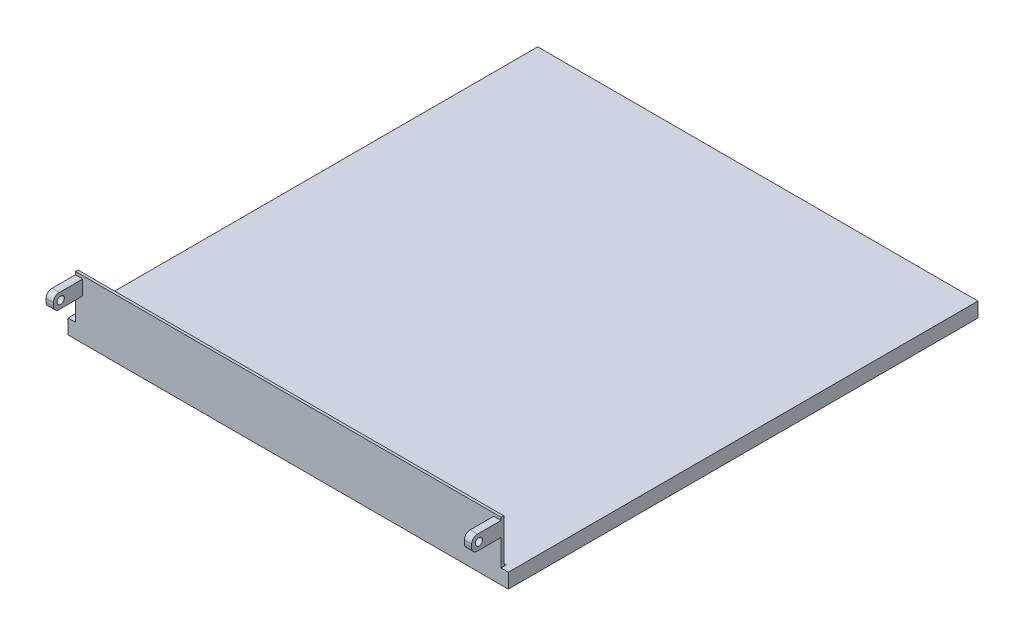
from build123d import *

# Parameters (mm, degrees)
SKETCH1_W                = 381
SKETCH1_H                = 406.4
BOSS_EXTRUDE1_DEPTH      = 12.7
CUT_EXTRUDE1_DEPTH       = 530.86
BOSS_EXTRUDE2_DEPTH      = 190.5
BOSS_EXTRUDE2_DEPTH_BACK = 190.5
CUT_EXTRUDE2_DEPTH       = 185.42
CUT_EXTRUDE2_DEPTH_BACK  = 185.42
SKETCH9_W                = 370.84
SKETCH9_H                = 38.1
BOSS_EXTRUDE3_DEPTH      = 203.2
SKETCH9_2_W              = 370.84
SKETCH9_2_H              = 38.1
CUT_EXTRUDE3_DEPTH       = 200.66
FILLET12_R               = 2.54
SKETCH20_W               = 381
SKETCH20_H               = 12.7
BOSS_EXTRUDE5_DEPTH      = 406.4
CUT_EXTRUDE10_DEPTH      = 304.8
CUT_EXTRUDE10_DEPTH_BACK = 259.334
SKETCH27_W               = 25.4
SKETCH27_H               = 12.7
SKETCH27_R               = 3.175
BOSS_EXTRUDE6_DEPTH      = 184.15
BOSS_EXTRUDE6_DEPTH_BACK = 184.15
SKETCH27_2_W             = 25.4
SKETCH27_2_H             = 12.7
SKETCH27_2_R             = 3.175
CUT_EXTRUDE11_DEPTH      = 177.8
CUT_EXTRUDE11_DEPTH_BACK = 177.8
FILLET14_R               = 5.08
SKETCH29_W               = 6.35
SKETCH29_H               = 38.1
CUT_EXTRUDE12_DEPTH      = 229.6
CUT_EXTRUDE12_DEPTH_BACK = 204.2000001


with BuildPart() as part:
    # Sketch1 → Boss-Extrude1 (new body)
    with BuildSketch(Plane(origin=(0, 0, 0), x_dir=(1, 0, 0), z_dir=(0, 1, 0))):
        Rectangle(SKETCH1_W, SKETCH1_H)
    extrude(amount=-BOSS_EXTRUDE1_DEPTH)

    # Sketch5 → Cut-Extrude1 (cut)
    with BuildSketch(Plane(origin=(0, 0, -203.2), x_dir=(-1, 0, 0), z_dir=(0, 0, -1))):
        Polygon((190.5, 0), (0, -12.7), (190.5, -12.7), align=None)
        Polygon((0, -12.7), (-190.5, 0), (-190.5, -12.7), align=None)
    extrude(amount=-CUT_EXTRUDE1_DEPTH, mode=Mode.SUBTRACT)

    # Sketch6 → Boss-Extrude2 (add, two sides)
    with BuildSketch(Plane(origin=(0, 0, 0), x_dir=(0, 0, -1), z_dir=(1, 0, 0))) as boss_extrude2_sk:
        with BuildLine():
            Line((-203.2, 0), (-203.2, 38.1))
            add(Edge.make_bspline(
                [(-203.2, 38.1), (-139.671233151, 43.854392756), (-4.575804842, 44.131584557), (127.011271564, 22.260123732), (203.2, 0)],
                knots=[0, 0, 0, 0, 0.446112954, 1, 1, 1, 1], degree=3))
            Line((203.2, 0), (-203.2, 0))
        make_face()
    extrude(amount=BOSS_EXTRUDE2_DEPTH)
    extrude(boss_extrude2_sk.sketch, amount=-BOSS_EXTRUDE2_DEPTH_BACK)

    # Sketch6_2 → Cut-Extrude2 (cut, two sides)
    with BuildSketch(Plane(origin=(0, 0, 0), x_dir=(0, 0, -1), z_dir=(1, 0, 0))) as cut_extrude2_sk:
        with BuildLine():
            Line((-203.2, 0), (-203.2, 38.1))
            add(Edge.make_bspline(
                [(-203.2, 38.1), (-139.671233151, 43.854392756), (-4.575804842, 44.131584557), (127.011271564, 22.260123732), (203.2, 0)],
                knots=[0, 0, 0, 0, 0.446112954, 1, 1, 1, 1], degree=3))
            Line((203.2, 0), (-203.2, 0))
        make_face()
    extrude(amount=CUT_EXTRUDE2_DEPTH, mode=Mode.SUBTRACT)
    extrude(cut_extrude2_sk.sketch, amount=-CUT_EXTRUDE2_DEPTH_BACK, mode=Mode.SUBTRACT)

    # Sketch9 → Boss-Extrude3 (add)
    with BuildSketch(Plane.XY):
        with Locations((0, 19.05)):
            Rectangle(SKETCH9_W, SKETCH9_H)
    extrude(amount=BOSS_EXTRUDE3_DEPTH)

    # Sketch9_2 → Cut-Extrude3 (cut)
    with BuildSketch(Plane.XY):
        with Locations((0, 19.05)):
            Rectangle(SKETCH9_2_W, SKETCH9_2_H)
    extrude(amount=CUT_EXTRUDE3_DEPTH, mode=Mode.SUBTRACT)

    # Fillet12
    fillet12_edges = [part.edges().sort_by_distance(p)[0] for p in [
        (0, 0, 200.66),
    ]]
    fillet(fillet12_edges, radius=FILLET12_R)

    # Sketch20 → Boss-Extrude5 (add)
    with BuildSketch(Plane.XY.offset(203.2)):
        with Locations((0, -6.35)):
            Rectangle(SKETCH20_W, SKETCH20_H)
    extrude(amount=-BOSS_EXTRUDE5_DEPTH)

    # Sketch21 → Cut-Extrude10 (cut, two sides)
    with BuildSketch(Plane(origin=(0, 0, 0), x_dir=(0, 0, -1), z_dir=(1, 0, 0))) as cut_extrude10_sk:
        with BuildLine():
            Line((-203.2, 38.1), (-203.2, 89.275464314))
            Line((-203.2, 89.275464314), (140.49634993, 63.687732157))
            Line((140.49634993, 63.687732157), (140.49634993, 16.247140788))
            add(Edge.make_bspline(
                [(-203.2, 38.1), (-32.059595942, 17.691928411), (140.49634993, 16.247140788)],
                knots=[0, 0, 0, 1, 1, 1], degree=2))
        make_face()
    extrude(amount=CUT_EXTRUDE10_DEPTH, mode=Mode.SUBTRACT)
    extrude(cut_extrude10_sk.sketch, amount=-CUT_EXTRUDE10_DEPTH_BACK, mode=Mode.SUBTRACT)

    # Sketch27 → Boss-Extrude6 (add, two sides)
    with BuildSketch(Plane(origin=(0, 0, 0), x_dir=(0, 0, -1), z_dir=(1, 0, 0))) as boss_extrude6_sk:
        with Locations((-215.9, 29.21)):
            Rectangle(SKETCH27_W, SKETCH27_H)
        with Locations((-222.25, 29.21)):
            Circle(SKETCH27_R, mode=Mode.SUBTRACT)
    extrude(amount=BOSS_EXTRUDE6_DEPTH)
    extrude(boss_extrude6_sk.sketch, amount=-BOSS_EXTRUDE6_DEPTH_BACK)

    # Sketch27_2 → Cut-Extrude11 (cut, two sides)
    with BuildSketch(Plane(origin=(0, 0, 0), x_dir=(0, 0, -1), z_dir=(1, 0, 0))) as cut_extrude11_sk:
        with Locations((-215.9, 29.21)):
            Rectangle(SKETCH27_2_W, SKETCH27_2_H)
        with Locations((-222.25, 29.21)):
            Circle(SKETCH27_2_R, mode=Mode.SUBTRACT)
    extrude(amount=CUT_EXTRUDE11_DEPTH, mode=Mode.SUBTRACT)
    extrude(cut_extrude11_sk.sketch, amount=-CUT_EXTRUDE11_DEPTH_BACK, mode=Mode.SUBTRACT)

    # Fillet14
    fillet14_edges = [part.edges().sort_by_distance(p)[0] for p in [
        (-180.975, 22.86, 228.6),
        (-180.975, 35.56, 228.6),
        (180.975, 35.56, 228.6),
        (180.975, 22.86, 228.6),
    ]]
    fillet(fillet14_edges, radius=FILLET14_R)

    # Sketch29 → Cut-Extrude12 (cut, two sides)
    with BuildSketch(Plane.XY) as cut_extrude12_sk:
        with Locations((-187.325, 19.05)):
            Rectangle(SKETCH29_W, SKETCH29_H)
        with Locations((187.325, 19.05)):
            Rectangle(SKETCH29_W, SKETCH29_H)
    extrude(amount=CUT_EXTRUDE12_DEPTH, mode=Mode.SUBTRACT)
    extrude(cut_extrude12_sk.sketch, amount=-CUT_EXTRUDE12_DEPTH_BACK, mode=Mode.SUBTRACT)


solid = part.part
